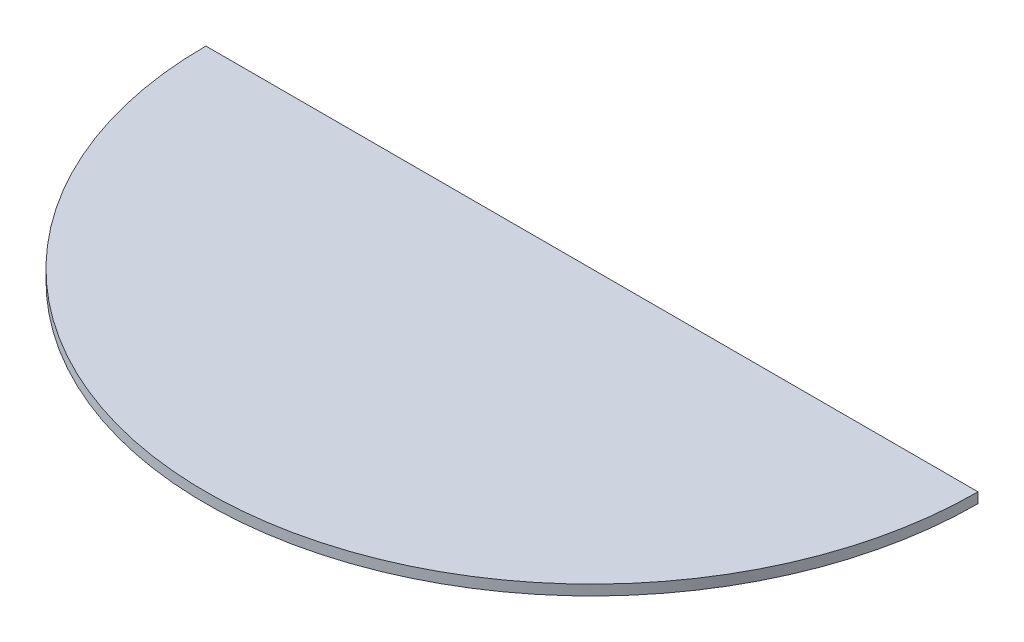
from build123d import *

# Parameters (mm, degrees)
BOSS_EXTRUDE1_DEPTH = 1


with BuildPart() as part:
    # Sketch1 → Boss-Extrude1 (new body, symmetric)
    with BuildSketch(Plane(origin=(0, 0, 0), x_dir=(1, 0, 0), z_dir=(0, 1, 0))):
        with BuildLine():
            Line((-75, 0), (75, 0))
            ThreePointArc((75, 0), (0, -75), (-75, 0))
        make_face()
    extrude(amount=BOSS_EXTRUDE1_DEPTH, both=True)


solid = part.part
